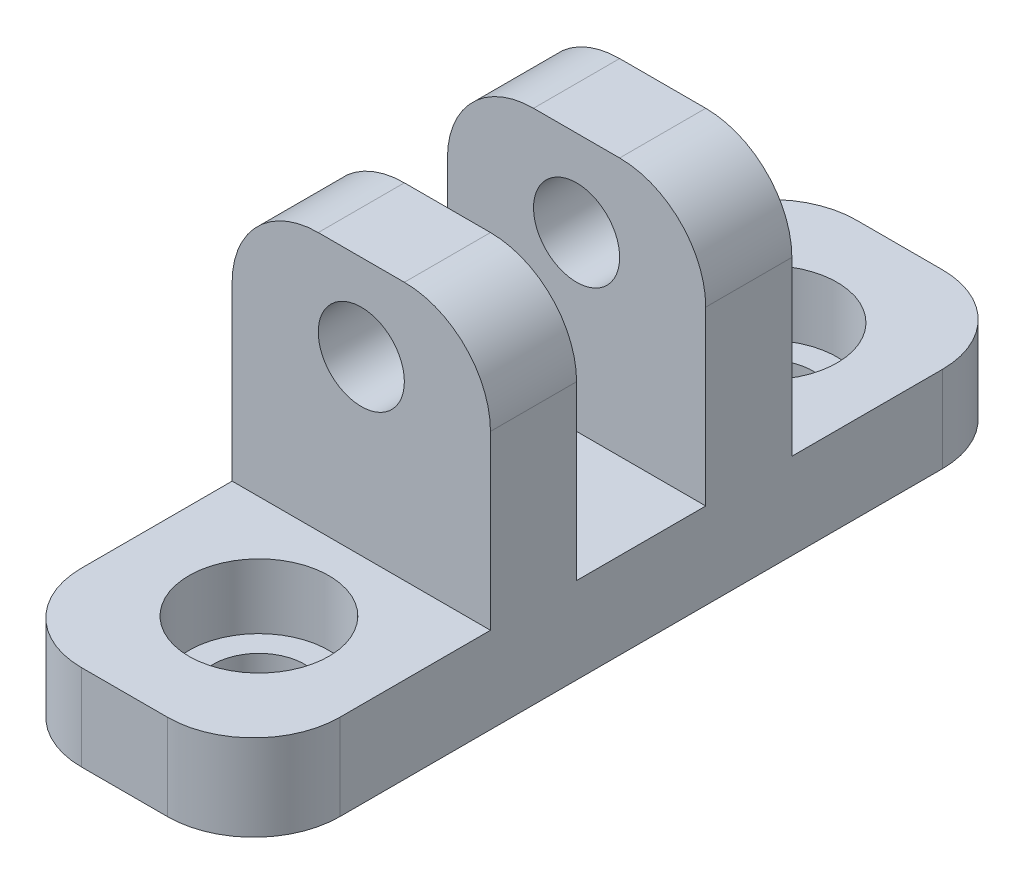
from build123d import *

# Parameters (mm, degrees)
SKETCH1_W                                        = 19.05
SKETCH1_H                                        = 57.15
BOSS_EXTRUDE1_DEPTH                              = 25.4
SKETCH2_W                                        = 17.4625
SKETCH2_H                                        = 19.05
SKETCH2_W_2                                      = 9.525
CUT_EXTRUDE1_DEPTH                               = 20.05
SKETCH9_R                                        = 3.175
CUT_EXTRUDE3_DEPTH                               = 40.6875
FILLET1_R                                        = 6.35
CBORE_FOR_1_4_SOCKET_SHOULDER_SCREW1_D           = 6.7564
CBORE_FOR_1_4_SOCKET_SHOULDER_SCREW1_CBORE_D     = 10.31748
CBORE_FOR_1_4_SOCKET_SHOULDER_SCREW1_CBORE_DEPTH = 4.7752


with BuildPart() as part:
    # Sketch1 → Boss-Extrude1 (new body)
    with BuildSketch(Plane(origin=(0, 0, 0), x_dir=(1, 0, 0), z_dir=(0, 1, 0))):
        with Locations((69.85, 0)):
            Rectangle(SKETCH1_W, SKETCH1_H)
    extrude(amount=BOSS_EXTRUDE1_DEPTH)

    # Sketch2 → Cut-Extrude1 (cut, through all)
    with BuildSketch(Plane(origin=(79.375, 0, 0), x_dir=(0, 0, -1), z_dir=(1, 0, 0))):
        with Locations((-19.84375, 15.875)):
            Rectangle(SKETCH2_W, SKETCH2_H)
        with Locations((0, 15.875)):
            Rectangle(SKETCH2_W_2, SKETCH2_H)
        with Locations((19.84375, 15.875)):
            Rectangle(SKETCH2_W, SKETCH2_H)
    extrude(amount=-CUT_EXTRUDE1_DEPTH, mode=Mode.SUBTRACT)

    # Sketch9 → Cut-Extrude3 (cut, through all)
    with BuildSketch(Plane.XY.offset(11.1125)):
        with Locations((69.85, 19.05)):
            Circle(SKETCH9_R)
    extrude(amount=-CUT_EXTRUDE3_DEPTH, mode=Mode.SUBTRACT)

    # Fillet1
    fillet1_edges = [part.edges().sort_by_distance(p)[0] for p in [
        (79.375, 25.4, 7.9375),
        (79.375, 3.175, 28.575),
        (60.325, 3.175, 28.575),
        (79.375, 25.4, -7.9375),
        (60.325, 25.4, -7.9375),
        (60.325, 25.4, 7.9375),
        (60.325, 3.175, -28.575),
        (79.375, 3.175, -28.575),
    ]]
    fillet(fillet1_edges, radius=FILLET1_R)

    # CBORE for 1/4 Socket Shoulder Screw1 (through all)
    with Locations(Plane(origin=(0, 6.35, 0), x_dir=(1, 0, 0), z_dir=(0, 1, 0))):
        with Locations((69.923370565, 18.735910675), (69.923370565, -18.735910675)):
            CounterBoreHole(CBORE_FOR_1_4_SOCKET_SHOULDER_SCREW1_D / 2, CBORE_FOR_1_4_SOCKET_SHOULDER_SCREW1_CBORE_D / 2, CBORE_FOR_1_4_SOCKET_SHOULDER_SCREW1_CBORE_DEPTH)


solid = part.part
